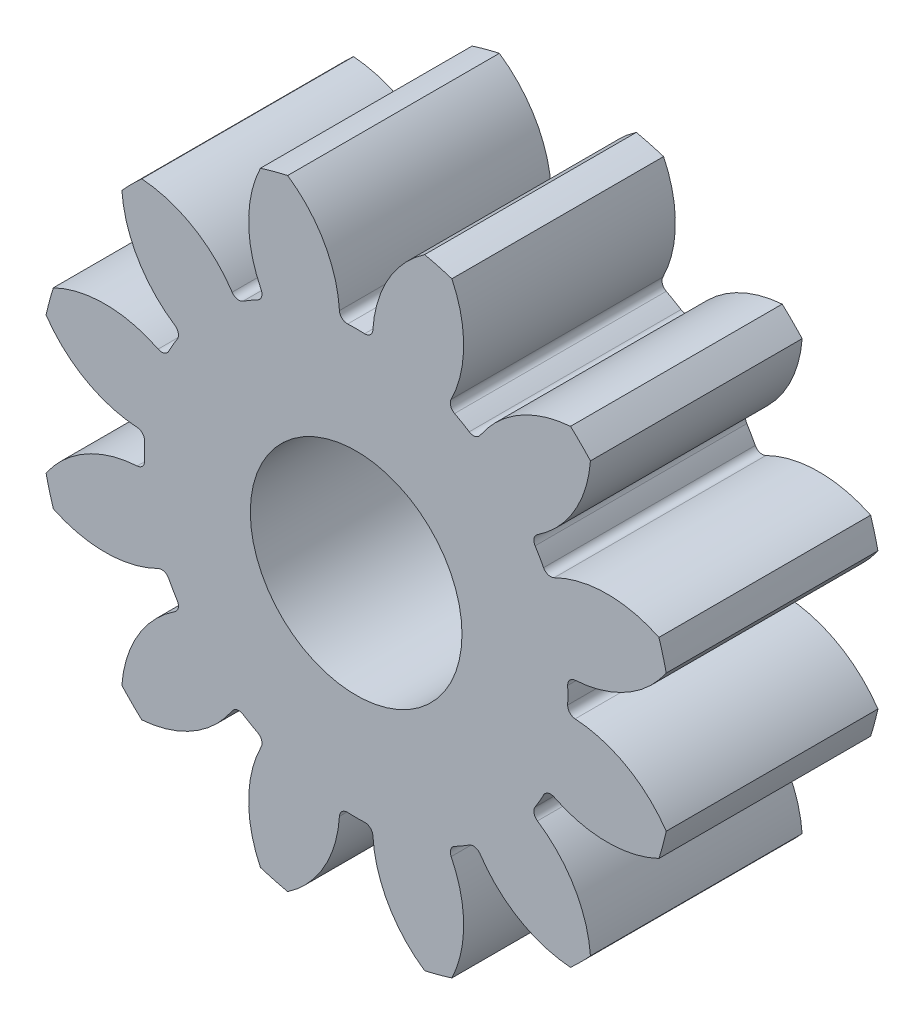
from build123d import *

# Parameters (mm, degrees)
SKETCH1_R           = 6
SKETCH1_R_2         = 2
BOSS_EXTRUDE1_DEPTH = 4
CUT_EXTRUDE2_DEPTH  = 5
CIRPATTERN2_COUNT   = 12


with BuildPart() as part:
    # Sketch1 → Boss-Extrude1 (new body)
    with BuildSketch(Plane.XY):
        Circle(SKETCH1_R)
        Circle(SKETCH1_R_2, mode=Mode.SUBTRACT)
    extrude(amount=BOSS_EXTRUDE1_DEPTH)

    # Sketch4 → Cut-Extrude2 (cut, through all)
    with BuildSketch(Plane.XY):
        with BuildLine():
            ThreePointArc((-0.160215471, 3.996790087), (-0.266788325, 4.035374045), (-0.315943185, 4.137502858))
            ThreePointArc((-0.315943185, 4.137502858), (-0.829511973, 5.435929685), (-2.010193861, 6.181352655))
            ThreePointArc((-2.010193861, 6.181352655), (0, 6.5), (2.010193861, 6.181352655))
            ThreePointArc((2.010193861, 6.181352655), (0.829511973, 5.435929685), (0.315943185, 4.137502858))
            ThreePointArc((0.315943185, 4.137502858), (0.266788325, 4.035374045), (0.160215471, 3.996790087))
            ThreePointArc((0.160215471, 3.996790087), (0, 4), (-0.160215471, 3.996790087))
        make_face()
    cut_extrude2 = extrude(amount=CUT_EXTRUDE2_DEPTH, mode=Mode.SUBTRACT)

    # CirPattern2: Cut-Extrude2 ×12 about axis
    cirpattern2_axis = Axis((0, 0, 0), (0, 0, 1))
    for i in range(1, CIRPATTERN2_COUNT):
        add(cut_extrude2.rotate(cirpattern2_axis, i * 360 / CIRPATTERN2_COUNT), mode=Mode.SUBTRACT)


solid = part.part
